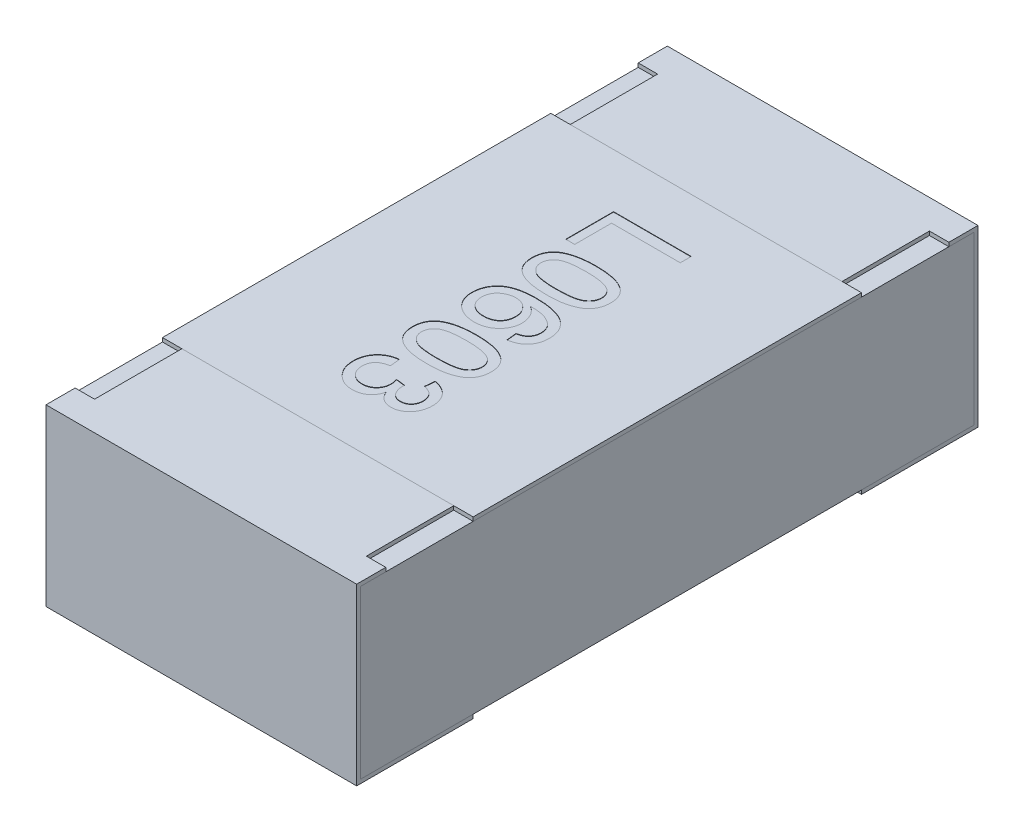
from build123d import *

# Parameters (mm, degrees)
BOSS_EXTRUDE2_DEPTH   = 0.4
BOSS_EXTRUDE2_2_DEPTH = 0.4
BOSS_EXTRUDE3_START   = -0.4
SKETCH5_W             = 1.58
SKETCH5_H             = 0.43
BOSS_EXTRUDE3_DEPTH   = 0.8
SKETCH6_W             = 0.05
SKETCH6_H             = 0.225
CUT_EXTRUDE1_DEPTH    = 0.01
SKETCH7_W             = 0.8
SKETCH7_H             = 1
BOSS_EXTRUDE4_DEPTH   = 0.01
TEXT0603_DEPTH        = 0.001


with BuildPart() as part:
    # Sketch4 → Boss-Extrude2 (new body, symmetric)
    with BuildSketch(Plane(origin=(0, 0, 0), x_dir=(0, 0, -1), z_dir=(1, 0, 0))):
        Polygon((-0.8, 0.225), (-0.8, -0.225), (-0.5, -0.225), (-0.5, -0.215), (-0.79, -0.215), (-0.79, 0.215), (-0.5, 0.215), (-0.5, 0.225), align=None)
    extrude(amount=BOSS_EXTRUDE2_DEPTH, both=True)


with BuildPart() as body_2:
    # Sketch4 → Boss-Extrude2 2 (new body, symmetric)
    with BuildSketch(Plane(origin=(0, 0, 0), x_dir=(0, 0, -1), z_dir=(1, 0, 0))):
        Polygon((0.5, 0.225), (0.8, 0.225), (0.8, -0.225), (0.5, -0.225), (0.5, -0.215), (0.79, -0.215), (0.79, 0.215), (0.5, 0.215), align=None)
    extrude(amount=BOSS_EXTRUDE2_2_DEPTH, both=True)


with BuildPart() as body_3:
    # Sketch5 → Boss-Extrude3 (new body)
    with BuildSketch(Plane(origin=(0, 0, 0), x_dir=(0, 0, -1), z_dir=(1, 0, 0)).offset(BOSS_EXTRUDE3_START)):
        Rectangle(SKETCH5_W, SKETCH5_H)
    extrude(amount=BOSS_EXTRUDE3_DEPTH)


with BuildPart() as cut_extrude1_tool:
    # Sketch6 → Cut-Extrude1 (new body)
    with BuildSketch(Plane(origin=(0, 0.225, 0), x_dir=(1, 0, 0), z_dir=(0, 1, 0))):
        with Locations((-0.375, 0.6125)):
            Rectangle(SKETCH6_W, SKETCH6_H)
        with Locations((0.375, 0.6125)):
            Rectangle(SKETCH6_W, SKETCH6_H)
        with Locations((0.375, -0.6125)):
            Rectangle(SKETCH6_W, SKETCH6_H)
        with Locations((-0.375, -0.6125)):
            Rectangle(SKETCH6_W, SKETCH6_H)
    extrude(amount=-CUT_EXTRUDE1_DEPTH)


with BuildPart() as part_1:
    add(part.part)

    # Cut-Extrude1: cut by cut_extrude1_tool
    add(cut_extrude1_tool.part, mode=Mode.SUBTRACT)


with BuildPart() as body_2_1:
    add(body_2.part)

    # Cut-Extrude1: cut by cut_extrude1_tool
    add(cut_extrude1_tool.part, mode=Mode.SUBTRACT)


with BuildPart() as body_4:
    # Sketch7 → Boss-Extrude4 (new body)
    with BuildSketch(Plane(origin=(0, 0.215, 0), x_dir=(1, 0, 0), z_dir=(0, 1, 0))):
        Rectangle(SKETCH7_W, SKETCH7_H)
    extrude(amount=BOSS_EXTRUDE4_DEPTH)

    # Sketch10 → TEXT0603 (cut)
    with BuildSketch(Plane(origin=(0, 0.225, 0), x_dir=(1, 0, 0), z_dir=(0, 1, 0))):
        Polygon((-0.1, 0.361538462), (0.1, 0.361538462), (0.1, 0.333333333), (-0.076923077, 0.333333333), (-0.076923077, 0.238461538), (-0.1, 0.238461538), align=None)
        with BuildLine():
            add(Edge.make_bspline(
                [(-0.001362179, 0.217948718), (0.001496004, 0.217922885), (0.007093982, 0.217872288), (0.01528483, 0.217558454), (0.023063338, 0.217010523), (0.030422754, 0.216192618), (0.03737968, 0.215224052), (0.043924224, 0.213964958), (0.050070943, 0.212548131), (0.055813865, 0.210848768), (0.061200859, 0.208979771), (0.066228535, 0.2068662), (0.070867156, 0.204467246), (0.075242692, 0.201999232), (0.079150183, 0.199125833), (0.082837127, 0.196211861), (0.086093066, 0.192959288), (0.089024575, 0.189522807), (0.091610645, 0.185845467), (0.093842323, 0.181948388), (0.095812677, 0.177846123), (0.097295972, 0.173460607), (0.098505168, 0.16888285), (0.099394669, 0.164077623), (0.099919059, 0.15903963), (0.099972715, 0.155596869), (0.1, 0.153846154)],
                knots=[0, 0, 0, 0, 8.575e-06, 1.6794e-05, 2.4587e-05, 3.1962e-05, 3.9005e-05, 4.5652e-05, 5.1949e-05, 5.7921e-05, 6.361e-05, 6.9049e-05, 7.4263e-05, 7.9273e-05, 8.4098e-05, 8.8797e-05, 9.3358e-05, 9.7877e-05, 0.000102335, 0.000106822, 0.000111338, 0.000115963, 0.000120686, 0.000125534, 0.000130609, 0.00013586, 0.00013586, 0.00013586, 0.00013586], degree=3))
            add(Edge.make_bspline(
                [(0.1, 0.153846154), (0.09992442, 0.151277672), (0.099775939, 0.146231787), (0.098566996, 0.138863985), (0.096493798, 0.131923289), (0.093718792, 0.125410786), (0.090129104, 0.119467294), (0.085877537, 0.114093824), (0.080786087, 0.109507489), (0.07502184, 0.105556789), (0.068573352, 0.102169064), (0.061501351, 0.099138605), (0.053775857, 0.096421516), (0.046880048, 0.094432725), (0.040917257, 0.093038407), (0.035990018, 0.092189507), (0.030689821, 0.091405726), (0.025003973, 0.090850171), (0.01895905, 0.090284849), (0.012528692, 0.090005743), (0.005717266, 0.089792743), (0.001041875, 0.089760281), (-0.001362179, 0.08974359)],
                knots=[0, 0, 0, 0, 7.703e-06, 1.5132e-05, 2.232e-05, 2.939e-05, 3.6309e-05, 4.3092e-05, 4.987e-05, 5.6782e-05, 6.4006e-05, 7.1686e-05, 7.9847e-05, 8.8558e-05, 9.3204e-05, 9.821e-05, 0.000103553, 0.000109274, 0.000115346, 0.000121764, 0.000128578, 0.00013579, 0.00013579, 0.00013579, 0.00013579], degree=3))
            add(Edge.make_bspline(
                [(-0.001362179, 0.08974359), (-0.00420696, 0.089769761), (-0.009764799, 0.089820893), (-0.017889658, 0.090128341), (-0.02561058, 0.090702165), (-0.032936981, 0.091441621), (-0.039875654, 0.092437205), (-0.046409619, 0.093681569), (-0.052546889, 0.095118813), (-0.058293654, 0.096745251), (-0.063657824, 0.098637494), (-0.06866507, 0.100771693), (-0.073364456, 0.103060185), (-0.07766846, 0.105655957), (-0.081648328, 0.108420609), (-0.085316591, 0.111379969), (-0.088621112, 0.114595335), (-0.09154299, 0.118063892), (-0.094175564, 0.121714982), (-0.096427535, 0.125622188), (-0.098306244, 0.129776371), (-0.099876447, 0.134140506), (-0.10106977, 0.138743561), (-0.10195578, 0.143561552), (-0.102484984, 0.148625911), (-0.102537366, 0.152082065), (-0.102564103, 0.153846154)],
                knots=[0, 0, 0, 0, 8.535e-06, 1.6674e-05, 2.4387e-05, 3.1758e-05, 3.8761e-05, 4.5408e-05, 5.1705e-05, 5.7665e-05, 6.3317e-05, 6.8757e-05, 7.3988e-05, 7.8984e-05, 8.3818e-05, 8.8517e-05, 9.3107e-05, 9.7627e-05, 0.000102107, 0.000106594, 0.00011113, 0.000115768, 0.000120491, 0.000125379, 0.000130454, 0.000135745, 0.000135745, 0.000135745, 0.000135745], degree=3))
            add(Edge.make_bspline(
                [(-0.102564103, 0.153846154), (-0.102498128, 0.156159027), (-0.102369495, 0.160668493), (-0.101495515, 0.167254236), (-0.099957268, 0.173435307), (-0.097894263, 0.17926384), (-0.095134874, 0.18467432), (-0.091777539, 0.189692581), (-0.087900369, 0.194419461), (-0.084841372, 0.19714054), (-0.083293269, 0.198517628)],
                knots=[0, 0, 0, 0, 6.938e-06, 1.3528e-05, 1.9883e-05, 2.6017e-05, 3.2037e-05, 3.8049e-05, 4.4107e-05, 5.0314e-05, 5.0314e-05, 5.0314e-05, 5.0314e-05], degree=3))
            add(Edge.make_bspline(
                [(-0.083293269, 0.198517628), (-0.081006797, 0.200102688), (-0.076291993, 0.20337115), (-0.068252815, 0.207196601), (-0.059402809, 0.210608971), (-0.049568339, 0.213287055), (-0.038827676, 0.215384663), (-0.027159744, 0.21689966), (-0.014569584, 0.217756999), (-0.005864031, 0.217883369), (-0.001362179, 0.217948718)],
                knots=[0, 0, 0, 0, 8.334e-06, 1.7185e-05, 2.662e-05, 3.6768e-05, 4.7713e-05, 5.9431e-05, 7.2042e-05, 8.5548e-05, 8.5548e-05, 8.5548e-05, 8.5548e-05], degree=3))
        make_face()
        with BuildLine():
            add(Edge.make_bspline(
                [(-0.001282051, 0.192307692), (-0.005128779, 0.192282233), (-0.012492266, 0.192233498), (-0.023012278, 0.191724334), (-0.032502764, 0.19084783), (-0.040950586, 0.189689034), (-0.048367169, 0.188158954), (-0.054733615, 0.186237758), (-0.060126334, 0.184072113), (-0.064478489, 0.181392169), (-0.06802613, 0.178457926), (-0.071077216, 0.17542852), (-0.07367057, 0.17223268), (-0.075832898, 0.16889126), (-0.07747007, 0.165352413), (-0.078656697, 0.161654837), (-0.079339582, 0.157797727), (-0.0794377, 0.155170861), (-0.079487179, 0.153846154)],
                knots=[0, 0, 0, 0, 1.154e-05, 2.2089e-05, 3.1585e-05, 4.0124e-05, 4.766e-05, 5.4275e-05, 6.0057e-05, 6.5039e-05, 6.9538e-05, 7.3844e-05, 7.7917e-05, 8.1862e-05, 8.5752e-05, 8.9578e-05, 9.3484e-05, 9.7458e-05, 9.7458e-05, 9.7458e-05, 9.7458e-05], degree=3))
            add(Edge.make_bspline(
                [(-0.079487179, 0.153846154), (-0.079436618, 0.152521779), (-0.079336357, 0.14989557), (-0.07866853, 0.146029548), (-0.077420817, 0.142346358), (-0.075789427, 0.138812788), (-0.073676385, 0.135447081), (-0.071073236, 0.132266937), (-0.068023961, 0.129221573), (-0.064435085, 0.126300511), (-0.060062809, 0.123640984), (-0.054674482, 0.121434714), (-0.048296887, 0.119543458), (-0.040884082, 0.118004983), (-0.032449618, 0.116841407), (-0.022985453, 0.115970202), (-0.012478977, 0.115457631), (-0.005128796, 0.1154097), (-0.001282051, 0.115384615)],
                knots=[0, 0, 0, 0, 3.974e-06, 7.88e-06, 1.1718e-05, 1.5608e-05, 1.9532e-05, 2.3605e-05, 2.7911e-05, 3.2442e-05, 3.7457e-05, 4.3202e-05, 4.9856e-05, 5.7392e-05, 6.5891e-05, 7.5387e-05, 8.5897e-05, 9.7436e-05, 9.7436e-05, 9.7436e-05, 9.7436e-05], degree=3))
            add(Edge.make_bspline(
                [(-0.001282051, 0.115384615), (0.002484656, 0.115408897), (0.009701523, 0.115455419), (0.020018863, 0.115981214), (0.029350069, 0.116805162), (0.037703671, 0.117932254), (0.045070832, 0.119429967), (0.051466511, 0.121247065), (0.056879301, 0.123410646), (0.06135668, 0.125988568), (0.065052608, 0.128846885), (0.068189367, 0.131883773), (0.070938214, 0.135040463), (0.073090618, 0.138497346), (0.0748559, 0.142107465), (0.076037637, 0.145948209), (0.076796066, 0.149969986), (0.076880121, 0.152720799), (0.076923077, 0.154126603)],
                knots=[0, 0, 0, 0, 1.1299e-05, 2.1649e-05, 3.0982e-05, 3.9396e-05, 4.6923e-05, 5.3516e-05, 5.9319e-05, 6.4363e-05, 6.8963e-05, 7.3298e-05, 7.7448e-05, 8.1483e-05, 8.5479e-05, 8.947e-05, 9.3502e-05, 9.7715e-05, 9.7715e-05, 9.7715e-05, 9.7715e-05], degree=3))
            add(Edge.make_bspline(
                [(0.076923077, 0.154126603), (0.076888311, 0.155451226), (0.076819756, 0.158063214), (0.076165406, 0.161887506), (0.075071185, 0.165511743), (0.073588958, 0.168977446), (0.071594172, 0.172198096), (0.069265118, 0.175301417), (0.066427425, 0.17814206), (0.064306011, 0.179853807), (0.063221154, 0.180729167)],
                knots=[0, 0, 0, 0, 3.971e-06, 7.831e-06, 1.1596e-05, 1.531e-05, 1.9103e-05, 2.2933e-05, 2.6927e-05, 3.1108e-05, 3.1108e-05, 3.1108e-05, 3.1108e-05], degree=3))
            add(Edge.make_bspline(
                [(0.063221154, 0.180729167), (0.061627835, 0.181682166), (0.058263081, 0.1836947), (0.052415001, 0.185946609), (0.045731758, 0.187935856), (0.038110526, 0.189573665), (0.029564378, 0.190758506), (0.02010324, 0.191693892), (0.009713902, 0.19217979), (0.002484394, 0.192263882), (-0.001282051, 0.192307692)],
                knots=[0, 0, 0, 0, 5.561e-06, 1.1743e-05, 1.8727e-05, 2.6476e-05, 3.5099e-05, 4.4599e-05, 5.4989e-05, 6.6289e-05, 6.6289e-05, 6.6289e-05, 6.6289e-05], degree=3))
        make_face(mode=Mode.SUBTRACT)
        with BuildLine():
            Line((0.048717949, -0.061538462), (0.046153846, -0.035897436))
            add(Edge.make_bspline(
                [(0.046153846, -0.035897436), (0.048359111, -0.035344123), (0.052510183, -0.034302597), (0.058140486, -0.032118527), (0.062902765, -0.029711728), (0.06546712, -0.027620743), (0.066666667, -0.026642628)],
                knots=[0, 0, 0, 0, 6.813e-06, 1.2825e-05, 1.8095e-05, 2.2726e-05, 2.2726e-05, 2.2726e-05, 2.2726e-05], degree=3))
            add(Edge.make_bspline(
                [(0.066666667, -0.026642628), (0.067484823, -0.025803031), (0.069093948, -0.024151736), (0.071191453, -0.021440912), (0.072968565, -0.018583254), (0.074408295, -0.015570127), (0.075545599, -0.012417807), (0.076341204, -0.009113238), (0.076833728, -0.005663906), (0.07689304, -0.003313616), (0.076923077, -0.002123397)],
                knots=[0, 0, 0, 0, 3.515e-06, 6.913e-06, 1.0259e-05, 1.3592e-05, 1.6912e-05, 2.0294e-05, 2.3773e-05, 2.7342e-05, 2.7342e-05, 2.7342e-05, 2.7342e-05], degree=3))
            add(Edge.make_bspline(
                [(0.076923077, -0.002123397), (0.076860948, -0.000193848), (0.076738183, 0.003618858), (0.075536329, 0.009212779), (0.073737563, 0.014646048), (0.071914142, 0.01801216), (0.07099359, 0.019711538)],
                knots=[0, 0, 0, 0, 5.78e-06, 1.1422e-05, 1.7098e-05, 2.2885e-05, 2.2885e-05, 2.2885e-05, 2.2885e-05], degree=3))
            add(Edge.make_bspline(
                [(0.07099359, 0.019711538), (0.069608433, 0.021382002), (0.066765039, 0.024811065), (0.061526643, 0.029295876), (0.055384929, 0.033244515), (0.049693495, 0.036214571), (0.044564387, 0.038274487), (0.040193981, 0.03968289), (0.035337576, 0.040813037), (0.030042438, 0.041775355), (0.02429006, 0.042513504), (0.018079873, 0.043132392), (0.011395209, 0.043474256), (0.00678452, 0.043550453), (0.004407051, 0.043589744)],
                knots=[0, 0, 0, 0, 6.501e-06, 1.3346e-05, 2.058e-05, 2.8374e-05, 3.2563e-05, 3.7149e-05, 4.2134e-05, 4.751e-05, 5.3289e-05, 5.9528e-05, 6.6229e-05, 7.3362e-05, 7.3362e-05, 7.3362e-05, 7.3362e-05], degree=3))
            add(Edge.make_bspline(
                [(0.004407051, 0.043589744), (0.006530318, 0.04207753), (0.010686742, 0.03911728), (0.01614183, 0.03389677), (0.02071144, 0.028160977), (0.024398078, 0.021973013), (0.02723058, 0.015469582), (0.029293949, 0.00879515), (0.030542464, 0.001943127), (0.030693258, -0.002679185), (0.030769231, -0.005008013)],
                knots=[0, 0, 0, 0, 7.813e-06, 1.5293e-05, 2.2564e-05, 2.9751e-05, 3.6837e-05, 4.3795e-05, 5.0672e-05, 5.7654e-05, 5.7654e-05, 5.7654e-05, 5.7654e-05], degree=3))
            add(Edge.make_bspline(
                [(0.030769231, -0.005008013), (0.030715427, -0.007013876), (0.030609129, -0.010976839), (0.02976185, -0.016811625), (0.028295929, -0.022397691), (0.026340359, -0.027787042), (0.02374514, -0.032908368), (0.020657985, -0.037848597), (0.016921948, -0.042497993), (0.012720699, -0.046918767), (0.008050779, -0.050944092), (0.003024369, -0.054506688), (-0.002370284, -0.057475552), (-0.008097131, -0.059882951), (-0.014135312, -0.061767163), (-0.020501978, -0.063136267), (-0.027209712, -0.063937722), (-0.031795387, -0.06404688), (-0.034134615, -0.064102564)],
                knots=[0, 0, 0, 0, 6.016e-06, 1.1886e-05, 1.7639e-05, 2.3317e-05, 2.9051e-05, 3.4831e-05, 4.0762e-05, 4.6912e-05, 5.3104e-05, 5.9229e-05, 6.5361e-05, 7.1538e-05, 7.7835e-05, 8.431e-05, 9.1049e-05, 9.8066e-05, 9.8066e-05, 9.8066e-05, 9.8066e-05], degree=3))
            add(Edge.make_bspline(
                [(-0.034134615, -0.064102564), (-0.037225822, -0.064002258), (-0.043326243, -0.063804307), (-0.052314529, -0.062231829), (-0.060955133, -0.059657436), (-0.067859389, -0.056703344), (-0.073059929, -0.053820249), (-0.076770639, -0.051504698), (-0.080223556, -0.048956696), (-0.083480916, -0.046259483), (-0.086434847, -0.043295453), (-0.089231066, -0.04023462), (-0.091706494, -0.036906996), (-0.094001953, -0.033447454), (-0.095987699, -0.029785264), (-0.097765603, -0.026022617), (-0.099251567, -0.022124601), (-0.100443275, -0.018101655), (-0.101418915, -0.013971823), (-0.102091513, -0.009713544), (-0.102505878, -0.005336891), (-0.102544544, -0.00237807), (-0.102564103, -0.00088141)],
                knots=[0, 0, 0, 0, 9.269e-06, 1.8293e-05, 2.728e-05, 3.6271e-05, 4.0754e-05, 4.5111e-05, 4.9382e-05, 5.3619e-05, 5.7784e-05, 6.1926e-05, 6.6045e-05, 7.0212e-05, 7.4372e-05, 7.853e-05, 8.2689e-05, 8.6872e-05, 9.1109e-05, 9.541e-05, 9.9796e-05, 0.000104284, 0.000104284, 0.000104284, 0.000104284], degree=3))
            add(Edge.make_bspline(
                [(-0.102564103, -0.00088141), (-0.102493836, 0.001646102), (-0.102356031, 0.006602998), (-0.101302468, 0.01385935), (-0.099525544, 0.020757091), (-0.09708891, 0.027308235), (-0.093939935, 0.033498627), (-0.090050422, 0.039306797), (-0.0854685, 0.04475774), (-0.080191835, 0.04985916), (-0.074080908, 0.054467597), (-0.067078821, 0.058485106), (-0.059127448, 0.061775862), (-0.050326016, 0.064555305), (-0.040591263, 0.066613144), (-0.029986068, 0.068200186), (-0.018469558, 0.069034926), (-0.010497956, 0.069163956), (-0.006370192, 0.069230769)],
                knots=[0, 0, 0, 0, 7.581e-06, 1.4867e-05, 2.1941e-05, 2.8914e-05, 3.5794e-05, 4.2728e-05, 4.9838e-05, 5.712e-05, 6.47e-05, 7.2741e-05, 8.1268e-05, 9.0467e-05, 0.000100393, 0.000111084, 0.000122617, 0.000135001, 0.000135001, 0.000135001, 0.000135001], degree=3))
            add(Edge.make_bspline(
                [(-0.006370192, 0.069230769), (-0.004019623, 0.069214651), (0.000615996, 0.069182865), (0.007444259, 0.068953927), (0.014029427, 0.068502515), (0.020362913, 0.067909171), (0.026454856, 0.067144677), (0.032301308, 0.066247284), (0.037894086, 0.065102344), (0.043245545, 0.063842577), (0.048359359, 0.062381153), (0.05324198, 0.060810673), (0.057857633, 0.058987985), (0.062234282, 0.057031706), (0.066365516, 0.054902943), (0.070267214, 0.05263666), (0.073889326, 0.050131477), (0.076158046, 0.04832979), (0.077283654, 0.047435897)],
                knots=[0, 0, 0, 0, 7.052e-06, 1.3907e-05, 2.0492e-05, 2.6851e-05, 3.2988e-05, 3.8909e-05, 4.459e-05, 5.011e-05, 5.5398e-05, 6.0542e-05, 6.549e-05, 7.0278e-05, 7.4919e-05, 7.9426e-05, 8.3805e-05, 8.8116e-05, 8.8116e-05, 8.8116e-05, 8.8116e-05], degree=3))
            add(Edge.make_bspline(
                [(0.077283654, 0.047435897), (0.079100398, 0.045820731), (0.082681369, 0.042637088), (0.087307136, 0.037190875), (0.091258253, 0.031387477), (0.094450413, 0.025134336), (0.096939124, 0.018479245), (0.098745707, 0.011418032), (0.099793401, 0.003930994), (0.099930017, -0.00118526), (0.1, -0.00380609)],
                knots=[0, 0, 0, 0, 7.285e-06, 1.436e-05, 2.1371e-05, 2.8306e-05, 3.5368e-05, 4.2646e-05, 5.013e-05, 5.7991e-05, 5.7991e-05, 5.7991e-05, 5.7991e-05], degree=3))
            add(Edge.make_bspline(
                [(0.1, -0.00380609), (0.099965504, -0.005757588), (0.099897732, -0.009591465), (0.099247462, -0.015209072), (0.098160632, -0.020552404), (0.096694621, -0.025633362), (0.094743172, -0.0304224), (0.092430494, -0.034974731), (0.089648488, -0.03924413), (0.086435162, -0.043199688), (0.082881605, -0.046851203), (0.078957976, -0.050121814), (0.074713177, -0.052999198), (0.07013838, -0.055505856), (0.065255241, -0.05761939), (0.060042771, -0.059354705), (0.054502312, -0.060673661), (0.050672796, -0.061246199), (0.048717949, -0.061538462)],
                knots=[0, 0, 0, 0, 5.853e-06, 1.1498e-05, 1.6935e-05, 2.2197e-05, 2.7338e-05, 3.2426e-05, 3.7494e-05, 4.2593e-05, 4.7693e-05, 5.2756e-05, 5.789e-05, 6.3054e-05, 6.8383e-05, 7.383e-05, 7.9515e-05, 8.5443e-05, 8.5443e-05, 8.5443e-05, 8.5443e-05], degree=3))
        make_face()
        with BuildLine():
            add(Edge.make_bspline(
                [(-0.033613782, 0.043589744), (-0.035621463, 0.043518424), (-0.039610467, 0.043376721), (-0.045531459, 0.042292857), (-0.051308467, 0.040522831), (-0.056877331, 0.038096989), (-0.06205137, 0.035101522), (-0.066635926, 0.031543605), (-0.070563686, 0.027500466), (-0.073843173, 0.022993835), (-0.076363368, 0.018034289), (-0.078188645, 0.012710655), (-0.079291848, 0.007016573), (-0.079421086, 0.003089892), (-0.079487179, 0.001081731)],
                knots=[0, 0, 0, 0, 6.02e-06, 1.1962e-05, 1.7994e-05, 2.4113e-05, 3.0146e-05, 3.5884e-05, 4.1465e-05, 4.7003e-05, 5.254e-05, 5.8089e-05, 6.3841e-05, 6.9861e-05, 6.9861e-05, 6.9861e-05, 6.9861e-05], degree=3))
            add(Edge.make_bspline(
                [(-0.079487179, 0.001081731), (-0.079448651, -0.00034938), (-0.079373447, -0.003142783), (-0.078785619, -0.007231638), (-0.07789718, -0.011124947), (-0.076537411, -0.014804434), (-0.074872898, -0.018295724), (-0.072792366, -0.021581435), (-0.070354139, -0.024662462), (-0.067542866, -0.027505563), (-0.064417088, -0.030075449), (-0.060994979, -0.03230825), (-0.057333114, -0.034280046), (-0.05334143, -0.035763146), (-0.049122211, -0.036971659), (-0.044635557, -0.037860147), (-0.039876317, -0.038381783), (-0.036606553, -0.038434568), (-0.034935897, -0.038461538)],
                knots=[0, 0, 0, 0, 4.292e-06, 8.377e-06, 1.2371e-05, 1.6249e-05, 2.0119e-05, 2.3954e-05, 2.789e-05, 3.1884e-05, 3.5927e-05, 4.0005e-05, 4.4127e-05, 4.8375e-05, 5.275e-05, 5.7284e-05, 6.208e-05, 6.7091e-05, 6.7091e-05, 6.7091e-05, 6.7091e-05], degree=3))
            add(Edge.make_bspline(
                [(-0.034935897, -0.038461538), (-0.033331604, -0.0384365), (-0.030194205, -0.038387535), (-0.02561586, -0.037837428), (-0.021288496, -0.037034385), (-0.01724491, -0.035807567), (-0.013460922, -0.034284381), (-0.00991239, -0.032448595), (-0.006642246, -0.030231868), (-0.00368572, -0.027649963), (-0.000997124, -0.024819668), (0.001355177, -0.021709223), (0.003304847, -0.018334759), (0.004934509, -0.014730063), (0.00617072, -0.010869885), (0.007029815, -0.006760048), (0.00762883, -0.00242134), (0.007670824, 0.000558758), (0.007692308, 0.002083333)],
                knots=[0, 0, 0, 0, 4.81e-06, 9.407e-06, 1.3815e-05, 1.7998e-05, 2.206e-05, 2.6038e-05, 2.9961e-05, 3.3881e-05, 3.7792e-05, 4.1654e-05, 4.555e-05, 4.9459e-05, 5.3501e-05, 5.7682e-05, 6.2045e-05, 6.6615e-05, 6.6615e-05, 6.6615e-05, 6.6615e-05], degree=3))
            add(Edge.make_bspline(
                [(0.007692308, 0.002083333), (0.007670171, 0.003501208), (0.007626548, 0.006295264), (0.007022434, 0.010392599), (0.006163151, 0.014342259), (0.004908687, 0.018125375), (0.003313336, 0.021744069), (0.001312084, 0.025176335), (-0.000996721, 0.028468559), (-0.003691508, 0.031532223), (-0.006612301, 0.034368456), (-0.009812536, 0.036838835), (-0.013231501, 0.03891878), (-0.016867826, 0.040678283), (-0.020749697, 0.041978976), (-0.024844946, 0.042900715), (-0.029150562, 0.043473101), (-0.032102895, 0.043550258), (-0.033613782, 0.043589744)],
                knots=[0, 0, 0, 0, 4.25e-06, 8.375e-06, 1.2399e-05, 1.6364e-05, 2.031e-05, 2.4241e-05, 2.8265e-05, 3.2354e-05, 3.6463e-05, 4.0462e-05, 4.4454e-05, 4.845e-05, 5.2555e-05, 5.6705e-05, 6.1028e-05, 6.556e-05, 6.556e-05, 6.556e-05, 6.556e-05], degree=3))
        make_face(mode=Mode.SUBTRACT)
        with BuildLine():
            add(Edge.make_bspline(
                [(-0.001362179, -0.08974359), (0.001496004, -0.089769423), (0.007093982, -0.08982002), (0.01528483, -0.090133854), (0.023063338, -0.090681784), (0.030422754, -0.091499689), (0.03737968, -0.092468256), (0.043924224, -0.093727349), (0.050070943, -0.095144177), (0.055813865, -0.096843539), (0.061200859, -0.098712536), (0.066228535, -0.100826108), (0.070867156, -0.103225062), (0.075242692, -0.105693075), (0.079150183, -0.108566474), (0.082837127, -0.111480446), (0.086093066, -0.11473302), (0.089024575, -0.1181695), (0.091610645, -0.121846841), (0.093842323, -0.12574392), (0.095812677, -0.129846185), (0.097295972, -0.134231701), (0.098505168, -0.138809458), (0.099394669, -0.143614685), (0.099919059, -0.148652678), (0.099972715, -0.152095438), (0.1, -0.153846154)],
                knots=[0, 0, 0, 0, 8.575e-06, 1.6794e-05, 2.4587e-05, 3.1962e-05, 3.9005e-05, 4.5652e-05, 5.1949e-05, 5.7921e-05, 6.361e-05, 6.9049e-05, 7.4263e-05, 7.9273e-05, 8.4098e-05, 8.8797e-05, 9.3358e-05, 9.7877e-05, 0.000102335, 0.000106822, 0.000111338, 0.000115963, 0.000120686, 0.000125534, 0.000130609, 0.00013586, 0.00013586, 0.00013586, 0.00013586], degree=3))
            add(Edge.make_bspline(
                [(0.1, -0.153846154), (0.09992442, -0.156414635), (0.099775939, -0.16146052), (0.098566996, -0.168828322), (0.096493798, -0.175769018), (0.093718792, -0.182281522), (0.090129104, -0.188225014), (0.085877537, -0.193598483), (0.080786087, -0.198184819), (0.07502184, -0.202135519), (0.068573352, -0.205523244), (0.061501351, -0.208553703), (0.053775857, -0.211270792), (0.046880048, -0.213259582), (0.040917257, -0.214653901), (0.035990018, -0.215502801), (0.030689821, -0.216286582), (0.025003973, -0.216842137), (0.01895905, -0.217407459), (0.012528692, -0.217686565), (0.005717266, -0.217899564), (0.001041875, -0.217932026), (-0.001362179, -0.217948718)],
                knots=[0, 0, 0, 0, 7.703e-06, 1.5132e-05, 2.232e-05, 2.939e-05, 3.6309e-05, 4.3092e-05, 4.987e-05, 5.6782e-05, 6.4006e-05, 7.1686e-05, 7.9847e-05, 8.8558e-05, 9.3204e-05, 9.821e-05, 0.000103553, 0.000109274, 0.000115346, 0.000121764, 0.000128578, 0.00013579, 0.00013579, 0.00013579, 0.00013579], degree=3))
            add(Edge.make_bspline(
                [(-0.001362179, -0.217948718), (-0.00420696, -0.217922546), (-0.009764799, -0.217871415), (-0.017889658, -0.217563967), (-0.02561058, -0.216990143), (-0.032936981, -0.216250687), (-0.039875654, -0.215255103), (-0.046409619, -0.214010738), (-0.052546889, -0.212573494), (-0.058293654, -0.210947057), (-0.063657824, -0.209054814), (-0.06866507, -0.206920615), (-0.073364456, -0.204632122), (-0.07766846, -0.20203635), (-0.081648328, -0.199271699), (-0.085316591, -0.196312339), (-0.088621112, -0.193096973), (-0.09154299, -0.189628415), (-0.094175564, -0.185977326), (-0.096427535, -0.18207012), (-0.098306244, -0.177915937), (-0.099876447, -0.173551801), (-0.10106977, -0.168948746), (-0.10195578, -0.164130756), (-0.102484984, -0.159066397), (-0.102537366, -0.155610243), (-0.102564103, -0.153846154)],
                knots=[0, 0, 0, 0, 8.535e-06, 1.6674e-05, 2.4387e-05, 3.1758e-05, 3.8761e-05, 4.5408e-05, 5.1705e-05, 5.7665e-05, 6.3317e-05, 6.8757e-05, 7.3988e-05, 7.8984e-05, 8.3818e-05, 8.8517e-05, 9.3107e-05, 9.7627e-05, 0.000102107, 0.000106594, 0.00011113, 0.000115768, 0.000120491, 0.000125379, 0.000130454, 0.000135745, 0.000135745, 0.000135745, 0.000135745], degree=3))
            add(Edge.make_bspline(
                [(-0.102564103, -0.153846154), (-0.102498128, -0.151533281), (-0.102369495, -0.147023814), (-0.101495515, -0.140438072), (-0.099957268, -0.134257001), (-0.097894263, -0.128428468), (-0.095134874, -0.123017987), (-0.091777539, -0.117999727), (-0.087900369, -0.113272847), (-0.084841372, -0.110551768), (-0.083293269, -0.109174679)],
                knots=[0, 0, 0, 0, 6.938e-06, 1.3528e-05, 1.9883e-05, 2.6017e-05, 3.2037e-05, 3.8049e-05, 4.4107e-05, 5.0314e-05, 5.0314e-05, 5.0314e-05, 5.0314e-05], degree=3))
            add(Edge.make_bspline(
                [(-0.083293269, -0.109174679), (-0.081006797, -0.107589619), (-0.076291993, -0.104321158), (-0.068252815, -0.100495707), (-0.059402809, -0.097083337), (-0.049568339, -0.094405252), (-0.038827676, -0.092307644), (-0.027159744, -0.090792648), (-0.014569584, -0.089935309), (-0.005864031, -0.089808939), (-0.001362179, -0.08974359)],
                knots=[0, 0, 0, 0, 8.334e-06, 1.7185e-05, 2.662e-05, 3.6768e-05, 4.7713e-05, 5.9431e-05, 7.2042e-05, 8.5548e-05, 8.5548e-05, 8.5548e-05, 8.5548e-05], degree=3))
        make_face()
        with BuildLine():
            add(Edge.make_bspline(
                [(-0.001282051, -0.115384615), (-0.005128779, -0.115410075), (-0.012492266, -0.11545881), (-0.023012278, -0.115967974), (-0.032502764, -0.116844478), (-0.040950586, -0.118003274), (-0.048367169, -0.119533353), (-0.054733615, -0.12145455), (-0.060126334, -0.123620194), (-0.064478489, -0.126300139), (-0.06802613, -0.129234382), (-0.071077216, -0.132263788), (-0.07367057, -0.135459627), (-0.075832898, -0.138801048), (-0.07747007, -0.142339895), (-0.078656697, -0.146037471), (-0.079339582, -0.14989458), (-0.0794377, -0.152521447), (-0.079487179, -0.153846154)],
                knots=[0, 0, 0, 0, 1.154e-05, 2.2089e-05, 3.1585e-05, 4.0124e-05, 4.766e-05, 5.4275e-05, 6.0057e-05, 6.5039e-05, 6.9538e-05, 7.3844e-05, 7.7917e-05, 8.1862e-05, 8.5752e-05, 8.9578e-05, 9.3484e-05, 9.7458e-05, 9.7458e-05, 9.7458e-05, 9.7458e-05], degree=3))
            add(Edge.make_bspline(
                [(-0.079487179, -0.153846154), (-0.079436618, -0.155170529), (-0.079336357, -0.157796738), (-0.07866853, -0.16166276), (-0.077420817, -0.165345949), (-0.075789427, -0.16887952), (-0.073676385, -0.172245227), (-0.071073236, -0.17542537), (-0.068023961, -0.178470734), (-0.064435085, -0.181391797), (-0.060062809, -0.184051324), (-0.054674482, -0.186257594), (-0.048296887, -0.188148849), (-0.040884082, -0.189687325), (-0.032449618, -0.190850901), (-0.022985453, -0.191722106), (-0.012478977, -0.192234677), (-0.005128796, -0.192282608), (-0.001282051, -0.192307692)],
                knots=[0, 0, 0, 0, 3.974e-06, 7.88e-06, 1.1718e-05, 1.5608e-05, 1.9532e-05, 2.3605e-05, 2.7911e-05, 3.2442e-05, 3.7457e-05, 4.3202e-05, 4.9856e-05, 5.7392e-05, 6.5891e-05, 7.5387e-05, 8.5897e-05, 9.7436e-05, 9.7436e-05, 9.7436e-05, 9.7436e-05], degree=3))
            add(Edge.make_bspline(
                [(-0.001282051, -0.192307692), (0.002484656, -0.192283411), (0.009701523, -0.192236889), (0.020018863, -0.191711094), (0.029350069, -0.190887145), (0.037703671, -0.189760054), (0.045070832, -0.188262341), (0.051466511, -0.186445242), (0.056879301, -0.184281662), (0.06135668, -0.18170374), (0.065052608, -0.178845423), (0.068189367, -0.175808534), (0.070938214, -0.172651844), (0.073090618, -0.169194961), (0.0748559, -0.165584843), (0.076037637, -0.161744099), (0.076796066, -0.157722322), (0.076880121, -0.154971509), (0.076923077, -0.153565705)],
                knots=[0, 0, 0, 0, 1.1299e-05, 2.1649e-05, 3.0982e-05, 3.9396e-05, 4.6923e-05, 5.3516e-05, 5.9319e-05, 6.4363e-05, 6.8963e-05, 7.3298e-05, 7.7448e-05, 8.1483e-05, 8.5479e-05, 8.947e-05, 9.3502e-05, 9.7715e-05, 9.7715e-05, 9.7715e-05, 9.7715e-05], degree=3))
            add(Edge.make_bspline(
                [(0.076923077, -0.153565705), (0.076888311, -0.152241082), (0.076819756, -0.149629094), (0.076165406, -0.145804802), (0.075071185, -0.142180565), (0.073588958, -0.138714862), (0.071594172, -0.135494211), (0.069265118, -0.132390891), (0.066427425, -0.129550247), (0.064306011, -0.1278385), (0.063221154, -0.126963141)],
                knots=[0, 0, 0, 0, 3.971e-06, 7.831e-06, 1.1596e-05, 1.531e-05, 1.9103e-05, 2.2933e-05, 2.6927e-05, 3.1108e-05, 3.1108e-05, 3.1108e-05, 3.1108e-05], degree=3))
            add(Edge.make_bspline(
                [(0.063221154, -0.126963141), (0.061627835, -0.126010142), (0.058263081, -0.123997608), (0.052415001, -0.121745699), (0.045731758, -0.119756452), (0.038110526, -0.118118642), (0.029564378, -0.116933802), (0.02010324, -0.115998416), (0.009713902, -0.115512518), (0.002484394, -0.115428426), (-0.001282051, -0.115384615)],
                knots=[0, 0, 0, 0, 5.561e-06, 1.1743e-05, 1.8727e-05, 2.6476e-05, 3.5099e-05, 4.4599e-05, 5.4989e-05, 6.6289e-05, 6.6289e-05, 6.6289e-05, 6.6289e-05], degree=3))
        make_face(mode=Mode.SUBTRACT)
        with BuildLine():
            Line((-0.046153846, -0.243589744), (-0.043589744, -0.269230769))
            add(Edge.make_bspline(
                [(-0.043589744, -0.269230769), (-0.045130197, -0.269573055), (-0.048110859, -0.270235352), (-0.052384427, -0.271501737), (-0.056333451, -0.272865898), (-0.059937194, -0.27445832), (-0.063222916, -0.27615357), (-0.06617001, -0.278050591), (-0.068791245, -0.280096588), (-0.071095703, -0.282305879), (-0.073078924, -0.284710886), (-0.07481674, -0.287276771), (-0.076253895, -0.290051322), (-0.077430092, -0.29301904), (-0.078333533, -0.29617578), (-0.079026142, -0.299521021), (-0.079430427, -0.303061558), (-0.079467953, -0.305487741), (-0.079487179, -0.306730769)],
                knots=[0, 0, 0, 0, 4.733e-06, 9.157e-06, 1.3364e-05, 1.7257e-05, 2.0967e-05, 2.4445e-05, 2.7755e-05, 3.0929e-05, 3.4001e-05, 3.7091e-05, 4.0209e-05, 4.3356e-05, 4.6652e-05, 5.0046e-05, 5.3595e-05, 5.7323e-05, 5.7323e-05, 5.7323e-05, 5.7323e-05], degree=3))
            add(Edge.make_bspline(
                [(-0.079487179, -0.306730769), (-0.079466391, -0.308188856), (-0.07942579, -0.311036502), (-0.078816627, -0.315185991), (-0.077980188, -0.319134962), (-0.076668604, -0.322827073), (-0.075065606, -0.326313735), (-0.07308464, -0.329575084), (-0.070758491, -0.332633444), (-0.068071335, -0.335428491), (-0.065115378, -0.337928094), (-0.061993133, -0.340154342), (-0.058677959, -0.34199515), (-0.05521655, -0.343546674), (-0.051552973, -0.344691901), (-0.047732911, -0.3455303), (-0.043739086, -0.346078198), (-0.041014121, -0.346128284), (-0.039623397, -0.346153846)],
                knots=[0, 0, 0, 0, 4.37e-06, 8.534e-06, 1.2558e-05, 1.6461e-05, 2.0261e-05, 2.4054e-05, 2.7884e-05, 3.1766e-05, 3.566e-05, 3.9483e-05, 4.325e-05, 4.7017e-05, 5.0844e-05, 5.4742e-05, 5.8742e-05, 6.2912e-05, 6.2912e-05, 6.2912e-05, 6.2912e-05], degree=3))
            add(Edge.make_bspline(
                [(-0.039623397, -0.346153846), (-0.038298972, -0.346129859), (-0.035706076, -0.346082898), (-0.031919984, -0.345514354), (-0.028295383, -0.34475577), (-0.024869669, -0.343561861), (-0.021593175, -0.342087787), (-0.018524677, -0.340228673), (-0.015593136, -0.338093257), (-0.012907152, -0.335610669), (-0.010413236, -0.332919605), (-0.008295348, -0.32996858), (-0.00646661, -0.326864536), (-0.00499021, -0.323568603), (-0.003818321, -0.320094962), (-0.002976077, -0.31644679), (-0.002492675, -0.312606585), (-0.002433889, -0.309990683), (-0.002403846, -0.308653846)],
                knots=[0, 0, 0, 0, 3.97e-06, 7.771e-06, 1.1465e-05, 1.5063e-05, 1.8631e-05, 2.2225e-05, 2.5806e-05, 2.9493e-05, 3.318e-05, 3.6794e-05, 4.0367e-05, 4.3972e-05, 4.7608e-05, 5.1349e-05, 5.5186e-05, 5.9195e-05, 5.9195e-05, 5.9195e-05, 5.9195e-05], degree=3))
            add(Edge.make_bspline(
                [(-0.002403846, -0.308653846), (-0.002435799, -0.30747695), (-0.002503971, -0.304966055), (-0.003076769, -0.301021689), (-0.003910239, -0.296657406), (-0.004707711, -0.293652007), (-0.005128205, -0.292067308)],
                knots=[0, 0, 0, 0, 3.529e-06, 7.53e-06, 1.1938e-05, 1.6854e-05, 1.6854e-05, 1.6854e-05, 1.6854e-05], degree=3))
            Line((-0.005128205, -0.292067308), (0.017948718, -0.294711538))
            add(Edge.make_bspline(
                [(0.017948718, -0.294711538), (0.017872906, -0.295405323), (0.017738973, -0.296631001), (0.017689666, -0.29786286), (0.017668269, -0.298397436)],
                knots=[0, 0, 0, 0, 2.093e-06, 3.698e-06, 3.698e-06, 3.698e-06, 3.698e-06], degree=3))
            add(Edge.make_bspline(
                [(0.017668269, -0.298397436), (0.01776111, -0.300741487), (0.01794426, -0.305365677), (0.01938377, -0.312105598), (0.021742507, -0.318486418), (0.024432843, -0.323454468), (0.027092795, -0.327074628), (0.029369252, -0.329433359), (0.031911562, -0.331447471), (0.034701733, -0.33308401), (0.037771566, -0.334329094), (0.041058287, -0.335264783), (0.044616166, -0.335767586), (0.047060551, -0.335853344), (0.048317308, -0.335897436)],
                knots=[0, 0, 0, 0, 7.028e-06, 1.3864e-05, 2.0569e-05, 2.7383e-05, 3.0733e-05, 3.4019e-05, 3.7185e-05, 4.0435e-05, 4.3687e-05, 4.7099e-05, 5.0663e-05, 5.4434e-05, 5.4434e-05, 5.4434e-05, 5.4434e-05], degree=3))
            add(Edge.make_bspline(
                [(0.048317308, -0.335897436), (0.049333617, -0.335878469), (0.05132123, -0.335841377), (0.05423548, -0.335428825), (0.056996062, -0.3347451), (0.059636008, -0.333825809), (0.062122109, -0.332606403), (0.064507489, -0.331160648), (0.066760853, -0.329437243), (0.068821985, -0.327418624), (0.070751604, -0.32525018), (0.072393378, -0.32285639), (0.073815359, -0.320332188), (0.07492082, -0.31763191), (0.075816656, -0.314806019), (0.076446724, -0.311827345), (0.076869234, -0.308692653), (0.076904877, -0.306545248), (0.076923077, -0.305448718)],
                knots=[0, 0, 0, 0, 3.047e-06, 5.96e-06, 8.807e-06, 1.1569e-05, 1.4329e-05, 1.7098e-05, 1.9926e-05, 2.2816e-05, 2.5741e-05, 2.862e-05, 3.1507e-05, 3.4416e-05, 3.7356e-05, 4.0389e-05, 4.354e-05, 4.6827e-05, 4.6827e-05, 4.6827e-05, 4.6827e-05], degree=3))
            add(Edge.make_bspline(
                [(0.076923077, -0.305448718), (0.076839405, -0.303302822), (0.076677822, -0.299158778), (0.075182843, -0.293225686), (0.072763773, -0.287849233), (0.069926879, -0.283868766), (0.067214648, -0.281042285), (0.064915719, -0.279111648), (0.062377032, -0.277384804), (0.05959949, -0.275856856), (0.056571924, -0.274548449), (0.05333184, -0.273368956), (0.049827366, -0.272455919), (0.04739911, -0.272018956), (0.046153846, -0.271794872)],
                knots=[0, 0, 0, 0, 6.428e-06, 1.2414e-05, 1.8223e-05, 2.4026e-05, 2.6973e-05, 2.9958e-05, 3.3014e-05, 3.617e-05, 3.9453e-05, 4.29e-05, 4.6505e-05, 5.03e-05, 5.03e-05, 5.03e-05, 5.03e-05], degree=3))
            Line((0.046153846, -0.271794872), (0.048717949, -0.246153846))
            add(Edge.make_bspline(
                [(0.048717949, -0.246153846), (0.050700542, -0.246554947), (0.054589554, -0.247341739), (0.060206331, -0.248944707), (0.065478946, -0.250899443), (0.070382943, -0.253246658), (0.074978026, -0.255874476), (0.079206037, -0.258908766), (0.083112881, -0.262271591), (0.086628043, -0.266013099), (0.089787707, -0.270000821), (0.092553833, -0.274238579), (0.094816784, -0.278743199), (0.096724764, -0.283468283), (0.098204844, -0.288430655), (0.099230897, -0.29363643), (0.099902079, -0.299060949), (0.099966958, -0.302762365), (0.1, -0.304647436)],
                knots=[0, 0, 0, 0, 6.067e-06, 1.19e-05, 1.7503e-05, 2.2916e-05, 2.8193e-05, 3.3363e-05, 3.8504e-05, 4.3633e-05, 4.8739e-05, 5.3751e-05, 5.8786e-05, 6.3837e-05, 6.9022e-05, 7.4294e-05, 7.974e-05, 8.5393e-05, 8.5393e-05, 8.5393e-05, 8.5393e-05], degree=3))
            add(Edge.make_bspline(
                [(0.1, -0.304647436), (0.099915731, -0.307257072), (0.099750032, -0.312388461), (0.098421251, -0.319936329), (0.096265676, -0.327161672), (0.093263457, -0.333989535), (0.089566746, -0.340281468), (0.085178489, -0.345868795), (0.080121604, -0.350657944), (0.07446947, -0.354553385), (0.068451006, -0.357637728), (0.062203742, -0.359920124), (0.05573467, -0.361283873), (0.051355117, -0.361453426), (0.049158654, -0.361538462)],
                knots=[0, 0, 0, 0, 7.825e-06, 1.5386e-05, 2.2915e-05, 3.0396e-05, 3.7707e-05, 4.4753e-05, 5.164e-05, 5.8519e-05, 6.5274e-05, 7.1877e-05, 7.8422e-05, 8.5007e-05, 8.5007e-05, 8.5007e-05, 8.5007e-05], degree=3))
            add(Edge.make_bspline(
                [(0.049158654, -0.361538462), (0.047082343, -0.361452253), (0.042982767, -0.361282038), (0.036988461, -0.359971586), (0.03130953, -0.357757182), (0.025926049, -0.354764139), (0.020954441, -0.350882897), (0.016524285, -0.346124117), (0.012593191, -0.340563926), (0.0105471, -0.336397032), (0.009495192, -0.334254808)],
                knots=[0, 0, 0, 0, 6.226e-06, 1.2292e-05, 1.8304e-05, 2.4456e-05, 3.0707e-05, 3.7141e-05, 4.3899e-05, 5.105e-05, 5.105e-05, 5.105e-05, 5.105e-05], degree=3))
            add(Edge.make_bspline(
                [(0.009495192, -0.334254808), (0.009132579, -0.33569103), (0.008422325, -0.338504169), (0.006950637, -0.342544421), (0.005227894, -0.346342922), (0.003275844, -0.349949236), (0.000970335, -0.353262261), (-0.001567703, -0.356390183), (-0.004403218, -0.359255474), (-0.00749831, -0.361873779), (-0.010833582, -0.364191195), (-0.014361375, -0.366248793), (-0.018105857, -0.367973389), (-0.022059553, -0.369385634), (-0.026218894, -0.370456954), (-0.030587838, -0.371208244), (-0.035138025, -0.371708118), (-0.038246512, -0.371765671), (-0.039823718, -0.371794872)],
                knots=[0, 0, 0, 0, 4.442e-06, 8.7e-06, 1.2877e-05, 1.6948e-05, 2.0982e-05, 2.4968e-05, 2.9019e-05, 3.3056e-05, 3.7113e-05, 4.1188e-05, 4.5293e-05, 4.9462e-05, 5.3767e-05, 5.816e-05, 6.2753e-05, 6.7483e-05, 6.7483e-05, 6.7483e-05, 6.7483e-05], degree=3))
            add(Edge.make_bspline(
                [(-0.039823718, -0.371794872), (-0.041976933, -0.371746052), (-0.046208691, -0.371650106), (-0.052425433, -0.370741126), (-0.058381161, -0.36925428), (-0.064099632, -0.367201489), (-0.069584684, -0.36458582), (-0.074815615, -0.361370621), (-0.079752311, -0.357522106), (-0.084424738, -0.35318317), (-0.088673552, -0.348385106), (-0.092392362, -0.343217285), (-0.095534914, -0.337739953), (-0.098100374, -0.331949729), (-0.100115223, -0.325858323), (-0.101559715, -0.319460661), (-0.102408613, -0.312736676), (-0.102511591, -0.30814881), (-0.102564103, -0.305809295)],
                knots=[0, 0, 0, 0, 6.456e-06, 1.2689e-05, 1.8801e-05, 2.4846e-05, 3.0885e-05, 3.7e-05, 4.3227e-05, 4.9633e-05, 5.6105e-05, 6.242e-05, 6.8701e-05, 7.5015e-05, 8.1388e-05, 8.7919e-05, 9.4662e-05, 0.000101679, 0.000101679, 0.000101679, 0.000101679], degree=3))
            add(Edge.make_bspline(
                [(-0.102564103, -0.305809295), (-0.102524399, -0.303709826), (-0.102446238, -0.299576686), (-0.101637368, -0.293525714), (-0.10047575, -0.287719516), (-0.098728161, -0.282213001), (-0.096534299, -0.276963649), (-0.093779244, -0.272035331), (-0.090599208, -0.267336115), (-0.086921266, -0.262960257), (-0.082861038, -0.258933336), (-0.078479445, -0.255340774), (-0.073785984, -0.252255833), (-0.068850939, -0.249535849), (-0.063581265, -0.247337399), (-0.05802221, -0.245625558), (-0.052194405, -0.244320256), (-0.048189274, -0.243835897), (-0.046153846, -0.243589744)],
                knots=[0, 0, 0, 0, 6.295e-06, 1.2392e-05, 1.8285e-05, 2.4038e-05, 2.9693e-05, 3.5324e-05, 4.0947e-05, 4.6692e-05, 5.2443e-05, 5.8081e-05, 6.3659e-05, 6.9271e-05, 7.4963e-05, 8.0754e-05, 8.6703e-05, 9.285e-05, 9.285e-05, 9.285e-05, 9.285e-05], degree=3))
        make_face()
    extrude(amount=-TEXT0603_DEPTH, mode=Mode.SUBTRACT)


solid = Compound([body_3.part, part_1.part, body_2_1.part, body_4.part])
